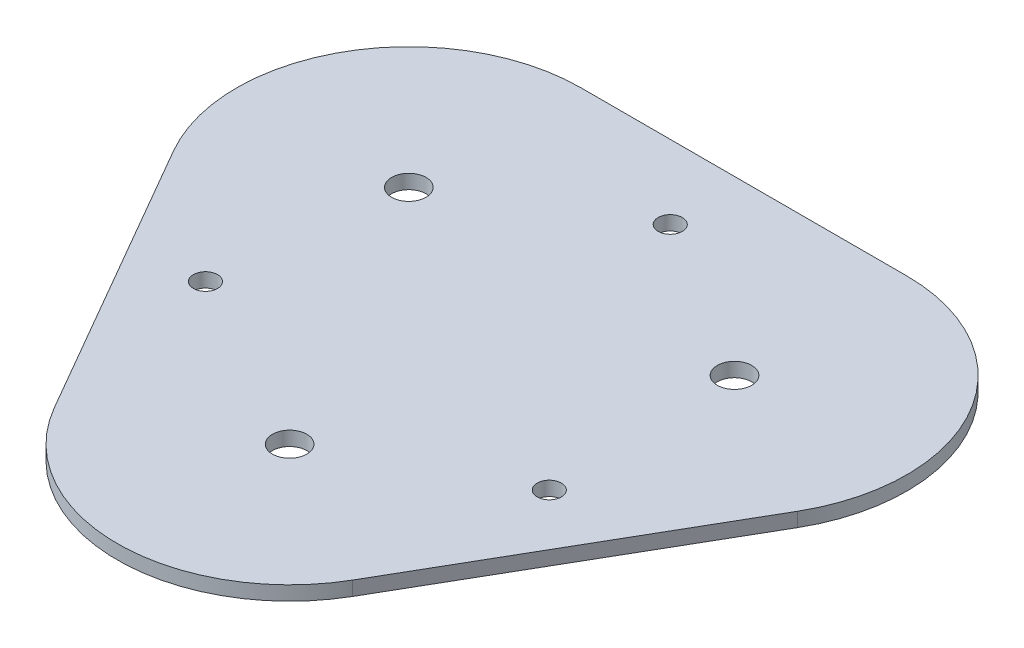
from build123d import *

# Parameters (mm, degrees)
SKETCH1_R           = 2
SKETCH1_R_2         = 1.4
BOSS_EXTRUDE1_DEPTH = 1.65
SKETCH2_W           = 5
SKETCH2_H           = 3
BOSS_EXTRUDE2_DEPTH = 4


with BuildPart() as part:
    # Sketch1 → Boss-Extrude1 (new body)
    with BuildSketch(Plane(origin=(0, 0, 0), x_dir=(1, 0, 0), z_dir=(0, 1, 0))):
        with BuildLine():
            Line((36.224008076, 0.913940814), (17.320508076, -31.827881627))
            ThreePointArc((17.320508076, -31.827881627), (0, -41.827881627), (-17.320508076, -31.827881627))
            Line((-17.320508076, -31.827881627), (-36.224008076, 0.913940814))
            ThreePointArc((-36.224008076, 0.913940814), (-36.224008076, 20.913940814), (-18.9035, 30.913940814))
            Line((-18.9035, 30.913940814), (18.9035, 30.913940814))
            ThreePointArc((18.9035, 30.913940814), (36.224008076, 20.913940814), (36.224008076, 0.913940814))
        make_face()
        with Locations((-18.9035, 10.913940814)):
            Circle(SKETCH1_R, mode=Mode.SUBTRACT)
        with Locations((18.9035, 10.913940814)):
            Circle(SKETCH1_R, mode=Mode.SUBTRACT)
        with Locations((0, -21.827881627)):
            Circle(SKETCH1_R, mode=Mode.SUBTRACT)
        with Locations((-21.238503314, -10.358710199)):
            Circle(SKETCH1_R_2, mode=Mode.SUBTRACT)
        with Locations((19.680254096, -11.3624)):
            Circle(SKETCH1_R_2, mode=Mode.SUBTRACT)
        with Locations((0, 22.3558)):
            Circle(SKETCH1_R_2, mode=Mode.SUBTRACT)
    extrude(amount=BOSS_EXTRUDE1_DEPTH)

    # Sketch2 → Boss-Extrude2 (add)
    with BuildSketch(Plane.XZ):
        Rectangle(SKETCH2_W, SKETCH2_H)
    extrude(amount=BOSS_EXTRUDE2_DEPTH)


solid = part.part
